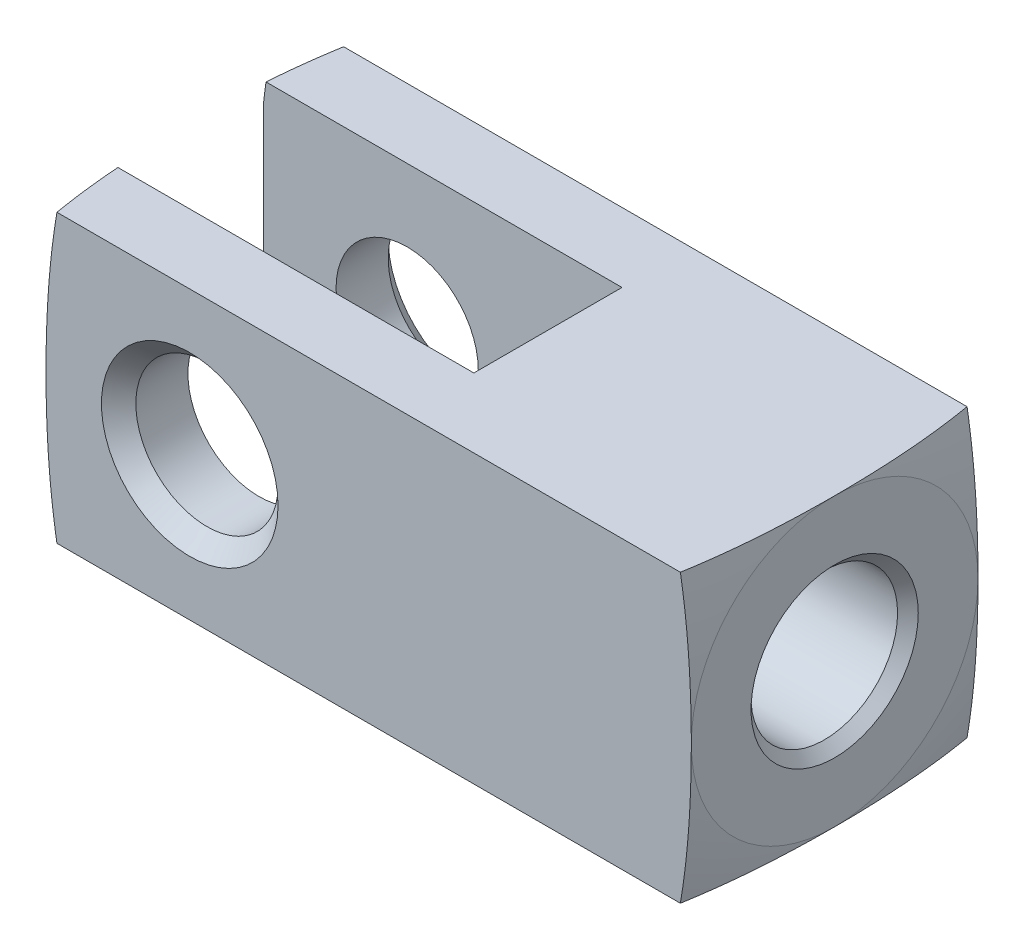
from build123d import *

# Parameters (mm, degrees)
BOSS_EXTRUDE1_DEPTH      = 9.525
BOSS_EXTRUDE1_DEPTH_BACK = 9.525
SKETCH1_W                = 42.8752
SKETCH1_H                = 19.05
CUT_EXTRUDE1_DEPTH       = 9.525
CUT_EXTRUDE1_DEPTH_BACK  = 9.525
SKETCH2_W                = 23.8252
SKETCH2_H                = 9.8425
HOLE1_D                  = 9.73836
HOLE1_DEPTH              = 15.748
HOLE1_CSINK_D            = 11.1125
HOLE1_CSINK_ANGLE        = 90
SKETCH5_W                = 4.96062
SKETCH5_H                = 3.302


with BuildPart() as part:
    # Sketch1 → Boss-Extrude1 (new, two sides: drawn at the far end of the back side and taken through both)
    with BuildSketch(Plane.XY.offset(-BOSS_EXTRUDE1_DEPTH_BACK)):
        with Locations((11.8872, 0)):
            Rectangle(SKETCH1_W, SKETCH1_H)
    extrude(amount=BOSS_EXTRUDE1_DEPTH + BOSS_EXTRUDE1_DEPTH_BACK)

    # Sketch2 → Cut-Extrude1 (cut, two sides: drawn at the far end of the back side and taken through both)
    with BuildSketch(Plane(origin=(0, 0, 0), x_dir=(1, 0, 0), z_dir=(0, 1, 0)).offset(-CUT_EXTRUDE1_DEPTH_BACK)):
        with Locations((2.3622, 0)):
            Rectangle(SKETCH2_W, SKETCH2_H)
    extrude(amount=CUT_EXTRUDE1_DEPTH + CUT_EXTRUDE1_DEPTH_BACK, mode=Mode.SUBTRACT)

    # Hole1
    with Locations(Plane(origin=(33.3248, 0, 0), x_dir=(0, 0, -1), z_dir=(1, 0, 0))):
        with Locations((0, 0)):
            CounterSinkHole(HOLE1_D / 2, HOLE1_CSINK_D / 2, depth=HOLE1_DEPTH, counter_sink_angle=HOLE1_CSINK_ANGLE)

    # Sketch5 → Hole2 (revolve, cut)
    with BuildSketch(Plane(origin=(17.5768, 0, 0), x_dir=(0, 0, -1), z_dir=(0, 1, 0))):
        with Locations((2.48031, 1.651)):
            Rectangle(SKETCH5_W, SKETCH5_H)
    revolve(axis=Axis((-92.4232, 0, 0), (1, 0, 0)), mode=Mode.SUBTRACT)

    # Sketch7 → Cut-Revolve1 (revolve, cut)
    with BuildSketch(Plane(origin=(0, 0, 0), x_dir=(0, 0, -1), z_dir=(1, 0, 0))):
        Polygon((-9.525, 0), (-9.525, 5.8674), (-8.382, 4.7244), (8.382, 4.7244), (9.525, 5.8674), (9.525, 0), align=None)
    revolve(axis=Axis((0, 0, -9.525), (0, 0, 1)), mode=Mode.SUBTRACT)

    # Sketch8 → Cut-Revolve2 (revolve, cut)
    with BuildSketch(Plane.XY):
        with BuildLine():
            Line((33.3248, 0), (33.3248, 9.525))
            ThreePointArc((33.3248, 9.525), (32.370901294, 14.371793679), (30.7848, 19.05))
            Line((30.7848, 19.05), (42.8498, 19.05))
            Line((42.8498, 19.05), (42.8498, 0))
            Line((42.8498, 0), (33.3248, 0))
        make_face()
    revolve(axis=Axis((42.8498, 0, 0), (-1, 0, 0)), mode=Mode.SUBTRACT)

    # Sketch9 → Cut-Revolve3 (revolve, cut)
    with BuildSketch(Plane.XY):
        with BuildLine():
            Line((-19.0754, 0), (-19.0754, 19.05))
            Line((-19.0754, 19.05), (-7.0104, 19.05))
            ThreePointArc((-7.0104, 19.05), (-8.596501294, 14.371793679), (-9.5504, 9.525))
            Line((-9.5504, 9.525), (-9.5504, 0))
            Line((-9.5504, 0), (-19.0754, 0))
        make_face()
    revolve(axis=Axis((-9.5504, 0, 0), (-1, 0, 0)), mode=Mode.SUBTRACT)


solid = part.part
